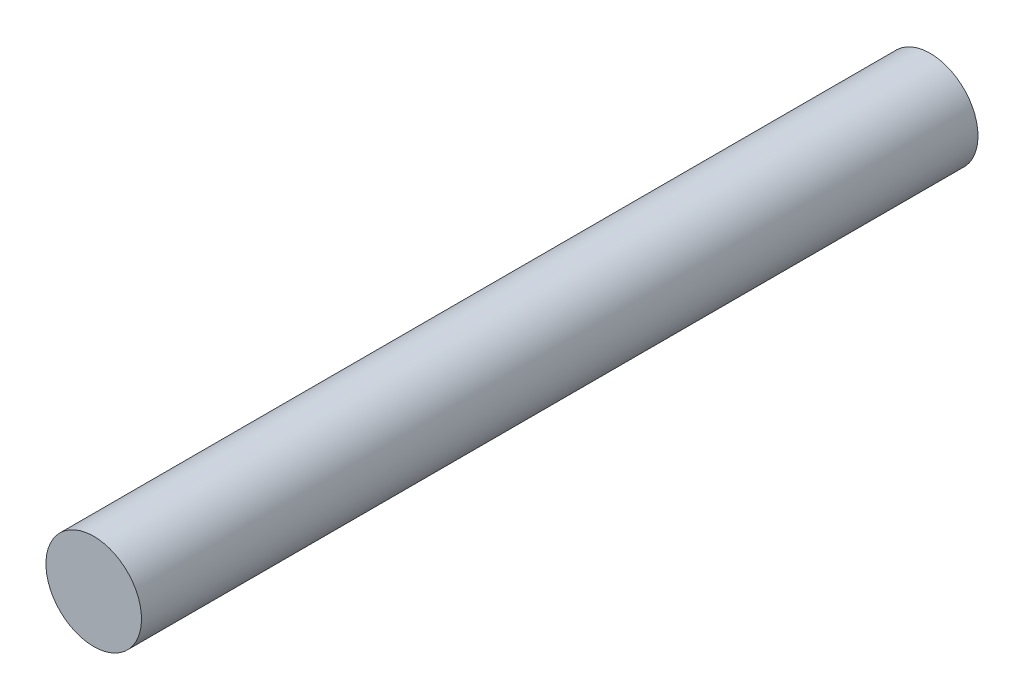
from build123d import *

# Parameters (mm, degrees)
SKETCH1_R           = 2
BOSS_EXTRUDE1_DEPTH = 35


with BuildPart() as part:
    # Sketch1 → Boss-Extrude1 (new body)
    with BuildSketch(Plane.XY):
        Circle(SKETCH1_R)
    extrude(amount=BOSS_EXTRUDE1_DEPTH)


solid = part.part
